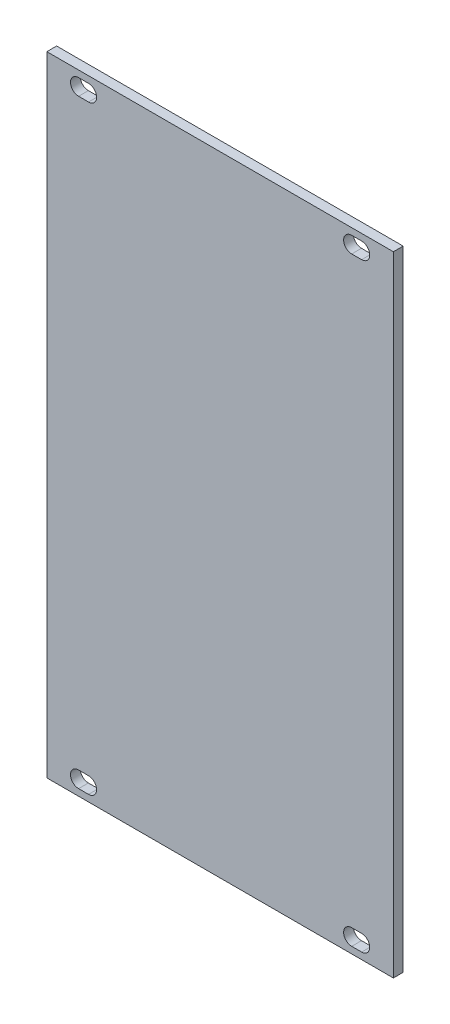
from build123d import *

# Parameters (mm, degrees)
SKETCH1_W           = 70.8
SKETCH1_H           = 128.5
BOSS_EXTRUDE1_DEPTH = 2


with BuildPart() as part:
    # Sketch1 → Boss-Extrude1 (new body)
    with BuildSketch(Plane.XY):
        Rectangle(SKETCH1_W, SKETCH1_H)
        with BuildLine():
            Line((-28.916, -59.6), (-26.884, -59.6))
            ThreePointArc((-26.884, -59.6), (-25.234, -61.25), (-26.884, -62.9))
            Line((-26.884, -62.9), (-28.916, -62.9))
            ThreePointArc((-28.916, -62.9), (-30.566, -61.25), (-28.916, -59.6))
        make_face(mode=Mode.SUBTRACT)
        with BuildLine():
            Line((-28.916, 62.9), (-26.884, 62.9))
            ThreePointArc((-26.884, 62.9), (-25.234, 61.25), (-26.884, 59.6))
            Line((-26.884, 59.6), (-28.916, 59.6))
            ThreePointArc((-28.916, 59.6), (-30.566, 61.25), (-28.916, 62.9))
        make_face(mode=Mode.SUBTRACT)
        with BuildLine():
            Line((26.884000014, 62.9), (28.916000014, 62.9))
            ThreePointArc((28.916000014, 62.9), (30.566000014, 61.25), (28.916000014, 59.6))
            Line((28.916000014, 59.6), (26.884000014, 59.6))
            ThreePointArc((26.884000014, 59.6), (25.234000014, 61.25), (26.884000014, 62.9))
        make_face(mode=Mode.SUBTRACT)
        with BuildLine():
            Line((26.884000014, -59.6), (28.916000014, -59.6))
            ThreePointArc((28.916000014, -59.6), (30.566000014, -61.25), (28.916000014, -62.9))
            Line((28.916000014, -62.9), (26.884000014, -62.9))
            ThreePointArc((26.884000014, -62.9), (25.234000014, -61.25), (26.884000014, -59.6))
        make_face(mode=Mode.SUBTRACT)
    extrude(amount=BOSS_EXTRUDE1_DEPTH)


solid = part.part
